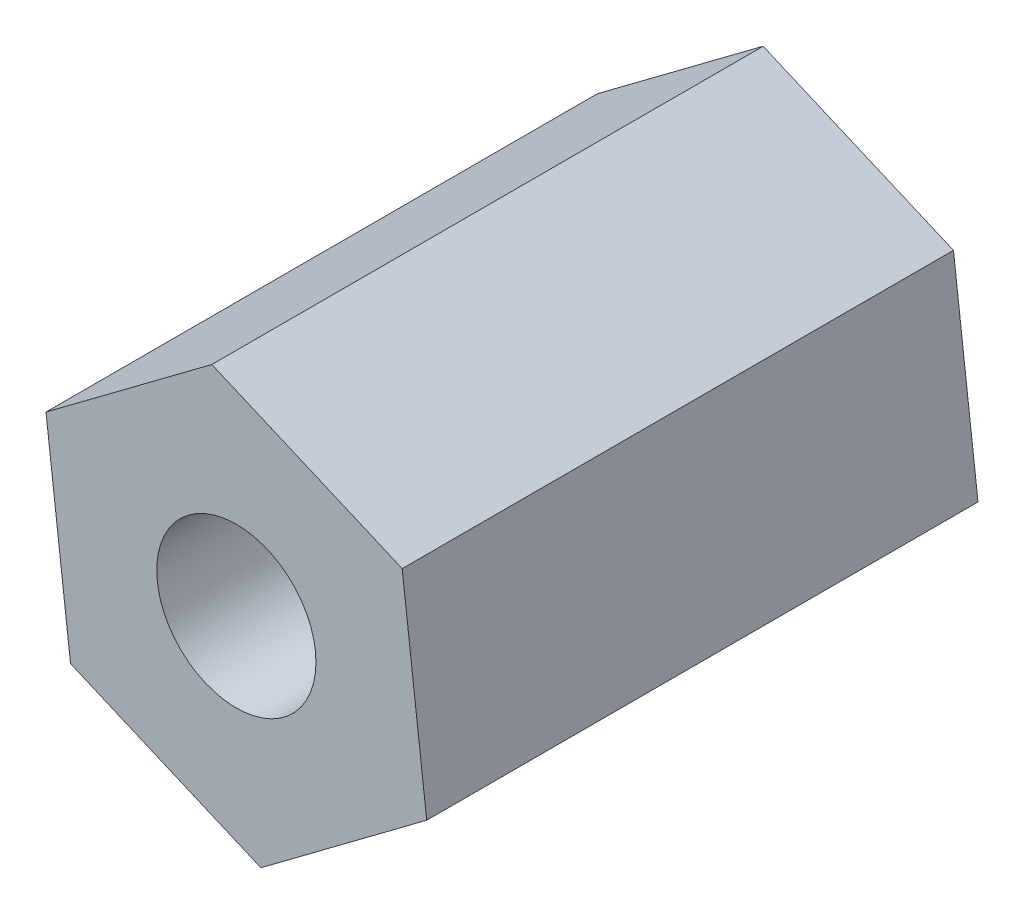
from build123d import *

# Parameters (mm, degrees)
SKETCH7_R           = 1.3716
BOSS_EXTRUDE4_DEPTH = 4.7498


with BuildPart() as part:
    # Sketch7 → Boss-Extrude4 (new, symmetric)
    with BuildSketch(Plane.XY):
        Polygon((-76.439762625, 4.738534743), (-76.86239804, 8.282120356), (-80.142550908, 9.687900156), (-83.000068362, 7.550094344), (-82.577432948, 4.006508731), (-79.297280079, 2.600728931), align=None)
        with Locations((-79.719915494, 6.144314544)):
            Circle(SKETCH7_R, mode=Mode.SUBTRACT)
    extrude(amount=BOSS_EXTRUDE4_DEPTH, both=True)


solid = part.part
